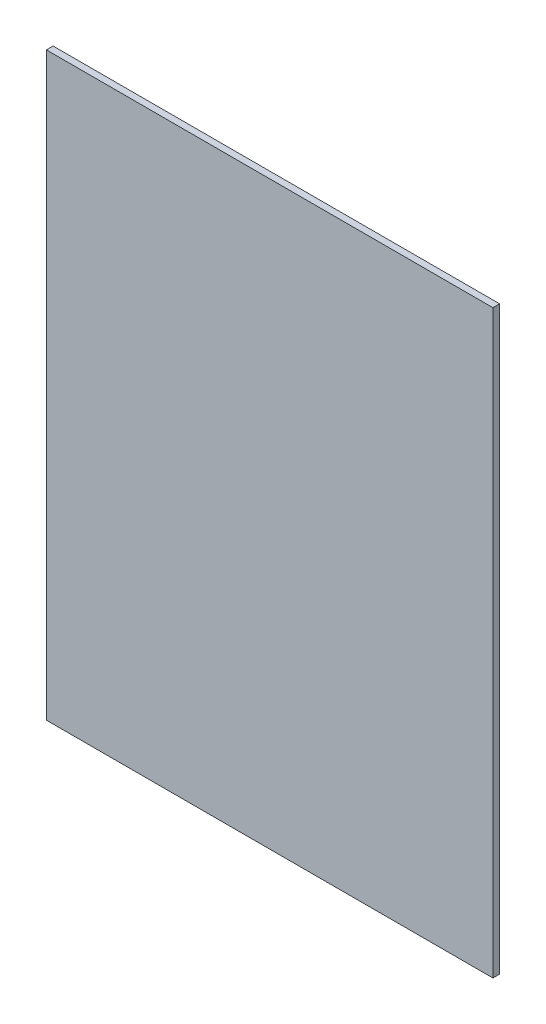
from build123d import *

# Parameters (mm, degrees)
ESBO_O1_W                = 200
ESBO_O1_H                = 260
RESSALTO_EXTRUS_O1_DEPTH = 3


with BuildPart() as part:
    # Esboço1 → Ressalto-extrusão1 (new body)
    with BuildSketch(Plane.XY):
        Rectangle(ESBO_O1_W, ESBO_O1_H)
    extrude(amount=RESSALTO_EXTRUS_O1_DEPTH)


solid = part.part
